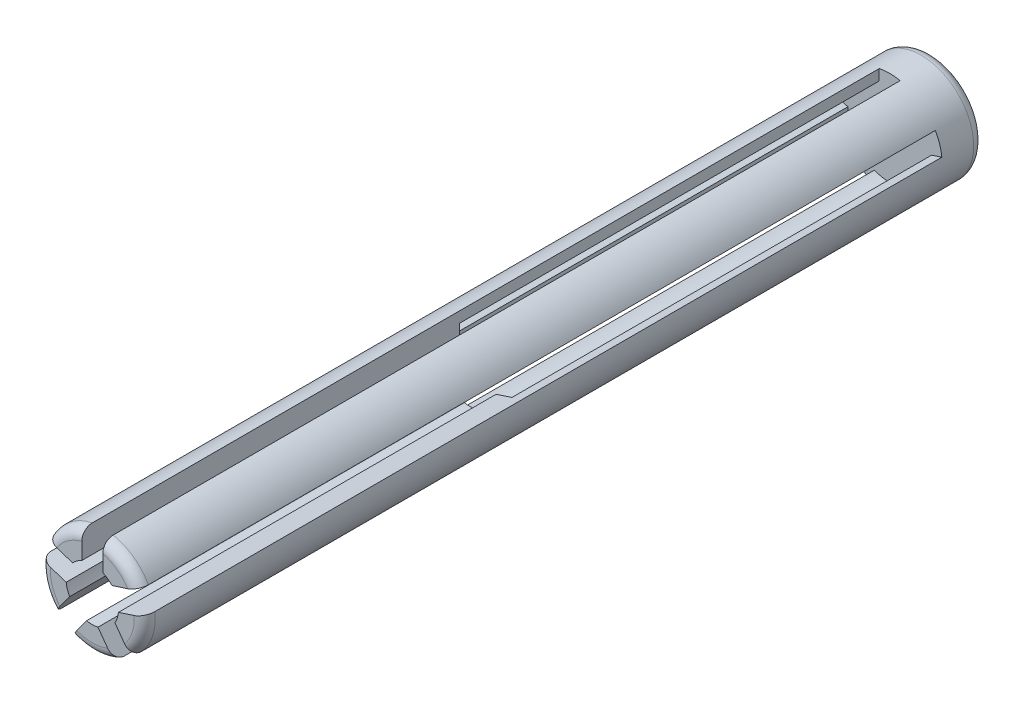
from build123d import *

# Parameters (mm, degrees)
SKETCH1_R           = 6.35
BOSS_EXTRUDE1_DEPTH = 101.6
FILLET1_R           = 1.27
SKETCH2_R           = 3.175
CUT_EXTRUDE1_DEPTH  = 45.72
SKETCH3_R           = 5.08
CUT_EXTRUDE2_DEPTH  = 50.8
FILLET2_R           = 1.27
CUT_EXTRUDE3_DEPTH  = 96.52


with BuildPart() as part:
    # Sketch1 → Boss-Extrude1 (new body)
    with BuildSketch(Plane.XY):
        Circle(SKETCH1_R)
    extrude(amount=BOSS_EXTRUDE1_DEPTH)

    # Fillet1
    fillet1_edges = [part.edges().sort_by_distance(p)[0] for p in [
        (-6.35, 0, 0),
    ]]
    fillet(fillet1_edges, radius=FILLET1_R)

    # Sketch2 → Cut-Extrude1 (cut)
    with BuildSketch(Plane.XY.offset(101.6)):
        Circle(SKETCH2_R)
    extrude(amount=-CUT_EXTRUDE1_DEPTH, mode=Mode.SUBTRACT)

    # Sketch3 → Cut-Extrude2 (cut)
    with BuildSketch(Plane.XY.offset(55.88)):
        Circle(SKETCH3_R)
    extrude(amount=-CUT_EXTRUDE2_DEPTH, mode=Mode.SUBTRACT)

    # Fillet2
    fillet2_edges = [part.edges().sort_by_distance(p)[0] for p in [
        (-6.35, 0, 101.6),
    ]]
    fillet(fillet2_edges, radius=FILLET2_R)

    # Sketch4 → Cut-Extrude3 (cut)
    with BuildSketch(Plane.XY.offset(101.6)):
        with BuildLine():
            Line((-1.27, 6.221703947), (-1.27, 2.909935566))
            Line((-1.27, 2.909935566), (1.27, 2.909935566))
            Line((1.27, 2.909935566), (1.27, 6.221703947))
            ThreePointArc((1.27, 6.221703947), (0, 6.35), (-1.27, 6.221703947))
        make_face()
        with BuildLine():
            Line((2.375061599, 2.107061318), (3.159964765, -0.308622233))
            Line((3.159964765, -0.308622233), (6.309643664, 0.714770478))
            ThreePointArc((6.309643664, 0.714770478), (6.039208878, 1.962257914), (5.524740498, 3.130454029))
            Line((5.524740498, 3.130454029), (2.375061599, 2.107061318))
        make_face()
        with BuildLine():
            Line((2.737868794, -1.607700055), (0.682965628, -3.100674596))
            Line((0.682965628, -3.100674596), (2.629574241, -5.779951497))
            ThreePointArc((2.629574241, -5.779951497), (3.732436352, -5.137257914), (4.684477407, -4.286976956))
            Line((4.684477407, -4.286976956), (2.737868794, -1.607700055))
        make_face()
        with BuildLine():
            Line((-0.682965628, -3.100674596), (-2.737868794, -1.607700055))
            Line((-2.737868794, -1.607700055), (-4.684477407, -4.286976956))
            ThreePointArc((-4.684477407, -4.286976956), (-3.732436352, -5.137257914), (-2.629574241, -5.779951497))
            Line((-2.629574241, -5.779951497), (-0.682965628, -3.100674596))
        make_face()
        with BuildLine():
            Line((-3.159964765, -0.308622233), (-2.375061599, 2.107061318))
            Line((-2.375061599, 2.107061318), (-5.524740498, 3.130454029))
            ThreePointArc((-5.524740498, 3.130454029), (-6.039208878, 1.962257914), (-6.309643664, 0.714770478))
            Line((-6.309643664, 0.714770478), (-3.159964765, -0.308622233))
        make_face()
    extrude(amount=-CUT_EXTRUDE3_DEPTH, mode=Mode.SUBTRACT)


solid = part.part
